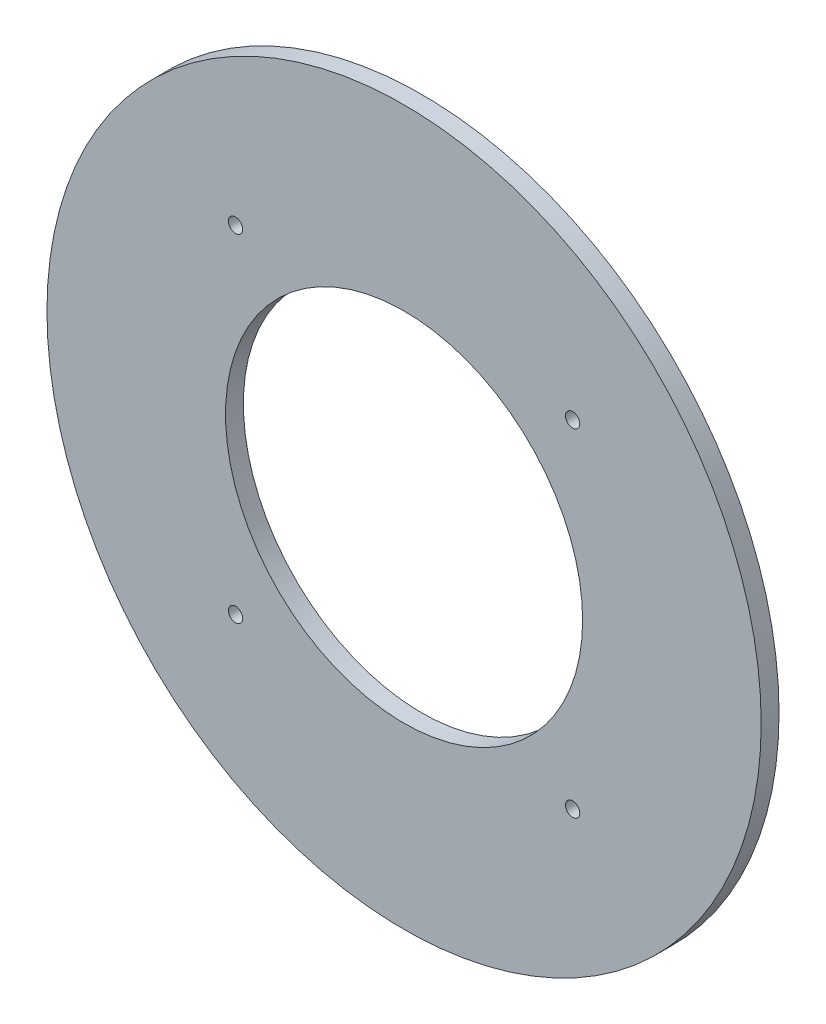
from build123d import *

# Parameters (mm, degrees)
SKETCH1_R           = 127
SKETCH1_R_2         = 63.5
SKETCH1_R_3         = 2.54
BOSS_EXTRUDE1_DEPTH = 6.35


with BuildPart() as part:
    # Sketch1 → Boss-Extrude1 (new body)
    with BuildSketch(Plane.XY):
        Circle(SKETCH1_R)
        Circle(SKETCH1_R_2, mode=Mode.SUBTRACT)
        with Locations((-59.944, 59.944)):
            Circle(SKETCH1_R_3, mode=Mode.SUBTRACT)
        with Locations((59.944, 59.944)):
            Circle(SKETCH1_R_3, mode=Mode.SUBTRACT)
        with Locations((-59.944, -59.944)):
            Circle(SKETCH1_R_3, mode=Mode.SUBTRACT)
        with Locations((59.944, -59.944)):
            Circle(SKETCH1_R_3, mode=Mode.SUBTRACT)
    extrude(amount=BOSS_EXTRUDE1_DEPTH)


solid = part.part
